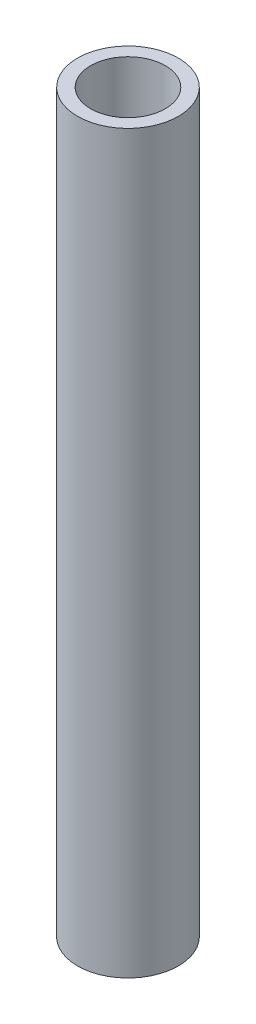
from build123d import *

# Parameters (mm, degrees)
SKETCH1_R           = 10.668
SKETCH1_R_2         = 7.8994
BOSS_EXTRUDE1_DEPTH = 155.575


with BuildPart() as part:
    # Sketch1 → Boss-Extrude1 (new body)
    with BuildSketch(Plane(origin=(0, 0, 0), x_dir=(1, 0, 0), z_dir=(0, 1, 0))):
        Circle(SKETCH1_R)
        Circle(SKETCH1_R_2, mode=Mode.SUBTRACT)
    extrude(amount=BOSS_EXTRUDE1_DEPTH)


solid = part.part
